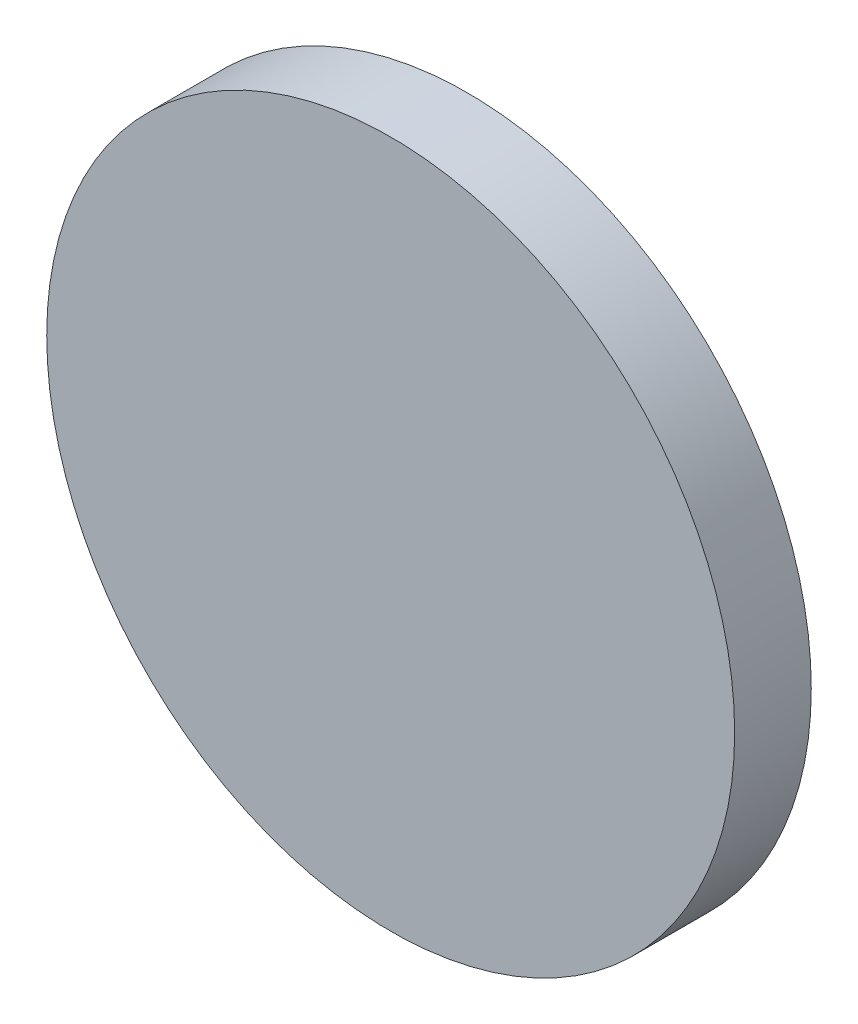
from build123d import *

# Parameters (mm, degrees)
SKETCH2_R           = 44.9
BOSS_EXTRUDE1_DEPTH = 10


with BuildPart() as part:
    # Sketch2 → Boss-Extrude1 (new body)
    with BuildSketch(Plane.XY):
        Circle(SKETCH2_R)
    extrude(amount=BOSS_EXTRUDE1_DEPTH)


solid = part.part
